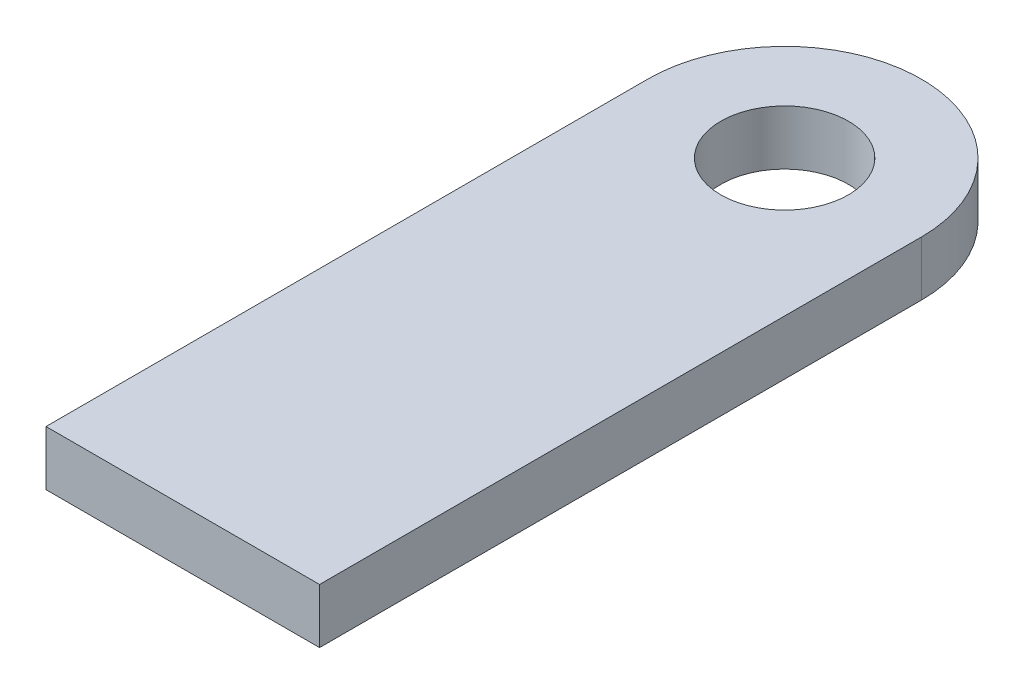
from build123d import *

# Parameters (mm, degrees)
SKETCH1_R           = 3.5
BOSS_EXTRUDE1_DEPTH = 3


with BuildPart() as part:
    # Sketch1 → Boss-Extrude1 (new body)
    with BuildSketch(Plane(origin=(0, 0, 0), x_dir=(1, 0, 0), z_dir=(0, 1, 0))):
        with BuildLine():
            Line((-8.711687898, 0.175603251), (-8.711687898, 33.175603251))
            ThreePointArc((-8.711687898, 33.175603251), (-1.211687898, 40.675603251), (6.288312102, 33.175603251))
            Line((6.288312102, 33.175603251), (6.288312102, 0.175603251))
            Line((6.288312102, 0.175603251), (-8.711687898, 0.175603251))
        make_face()
        with Locations((-1.211687898, 33.175603251)):
            Circle(SKETCH1_R, mode=Mode.SUBTRACT)
    extrude(amount=BOSS_EXTRUDE1_DEPTH)


solid = part.part
